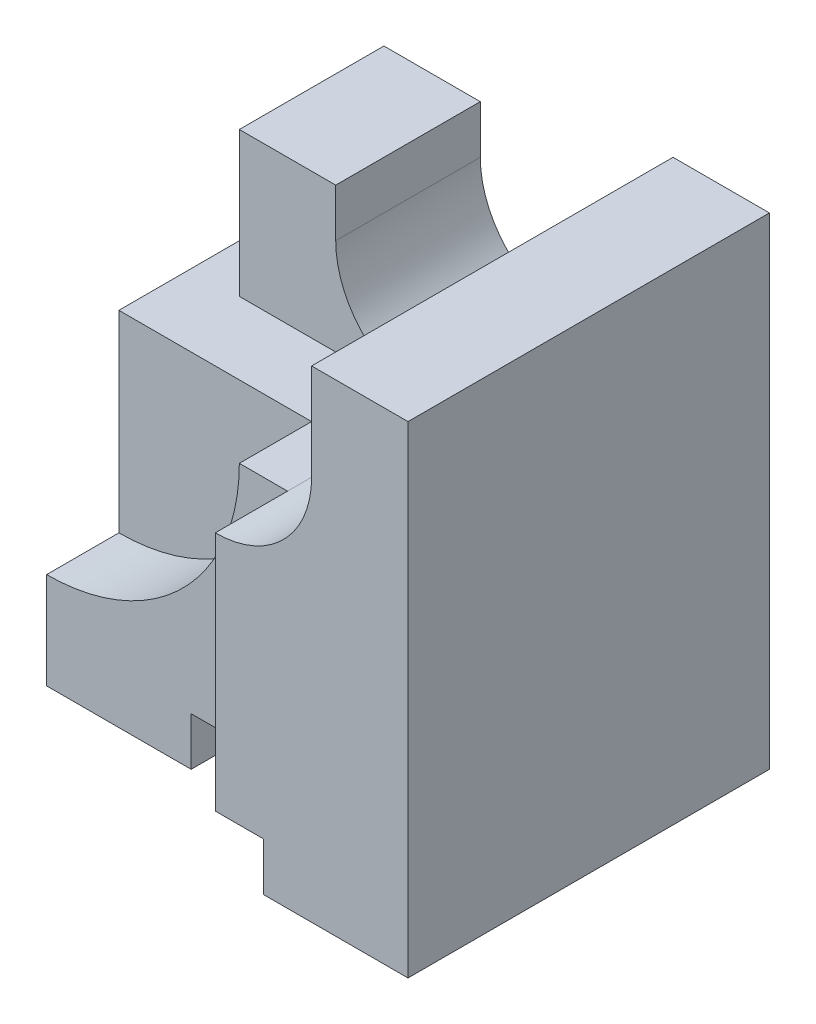
from build123d import *

# Parameters (mm, degrees)
BOSS_EXTRUDE1_DEPTH = 3.75
SKETCH2_W           = 4
SKETCH2_H           = 4.100690398
CUT_EXTRUDE1_DEPTH  = 4.5
SKETCH3_W           = 5
SKETCH3_H           = 9.939403745
CUT_EXTRUDE2_DEPTH  = 1.5
CUT_EXTRUDE3_DEPTH  = 1.5


with BuildPart() as part:
    # Sketch1 → Boss-Extrude1 (new body, symmetric)
    with BuildSketch(Plane.XY):
        with BuildLine():
            Line((0, 6), (0, 0))
            Line((0, 0), (3, 0))
            Line((3, 0), (3, 1))
            Line((3, 1), (6, 1))
            Line((6, 1), (6, 0))
            Line((6, 0), (9, 0))
            Line((9, 0), (9, 10))
            Line((9, 10), (7, 10))
            Line((7, 10), (7, 8))
            ThreePointArc((7, 8), (5, 6), (3, 8))
            Line((3, 8), (3, 9))
            Line((3, 9), (1, 9))
            Line((1, 9), (1, 6))
            Line((1, 6), (0, 6))
        make_face()
    extrude(amount=BOSS_EXTRUDE1_DEPTH, both=True)

    # Sketch2 → Cut-Extrude1 (cut)
    with BuildSketch(Plane.XY.offset(3.75)):
        with Locations((3, 8.050345199)):
            Rectangle(SKETCH2_W, SKETCH2_H)
    extrude(amount=-CUT_EXTRUDE1_DEPTH, mode=Mode.SUBTRACT)

    # Sketch3 → Cut-Extrude2 (cut)
    with BuildSketch(Plane.XY.offset(3.75)):
        with Locations((2.5, 4.969701872)):
            Rectangle(SKETCH3_W, SKETCH3_H)
    extrude(amount=-CUT_EXTRUDE2_DEPTH, mode=Mode.SUBTRACT)

    # Sketch4 → Cut-Extrude3 (cut)
    with BuildSketch(Plane.XY.offset(2.25)):
        with BuildLine():
            Line((4, 6), (0, 6))
            Line((0, 6), (0, 2))
            ThreePointArc((0, 2), (2.828427125, 3.171572875), (4, 6))
        make_face()
    extrude(amount=-CUT_EXTRUDE3_DEPTH, mode=Mode.SUBTRACT)


solid = part.part
